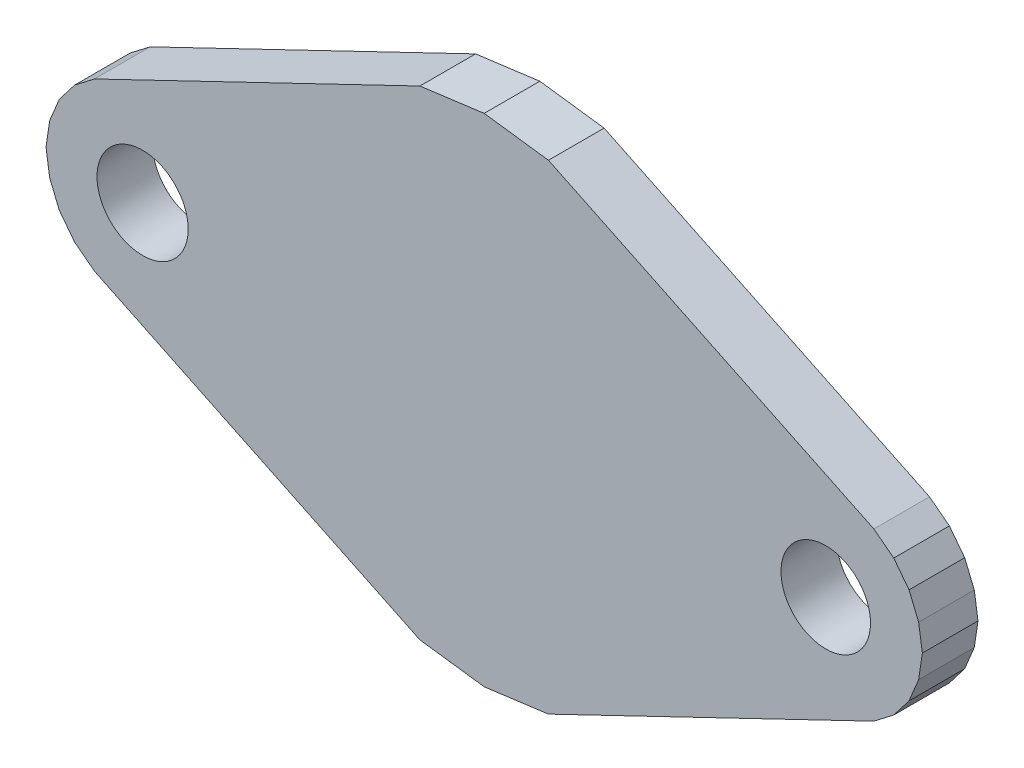
from build123d import *

# Parameters (mm, degrees)
ESBO_O1_R                = 2.458273609
ESBO_O1_R_2              = 2.41299998
RESSALTO_EXTRUS_O2_DEPTH = 3


with BuildPart() as part:
    # Esboço1 → Ressalto-extrusão2 (new body)
    with BuildSketch(Plane.XY):
        Polygon((-3.440879294, 5.164211145), (0.023622001, 5.620321217), (0.023622001, -21.15127821), (-3.440879351, -20.69516813), (-20.982927009, -12.254172046), (-22.056381633, -11.43048149), (-22.880072189, -10.357026984), (-23.397865785, -9.106962052), (-23.598378589, -7.765478496), (-23.397865785, -6.423994009), (-22.880072189, -5.173929077), (-22.056381633, -4.100475502), (-20.982927009, -3.276784015), align=None)
        with Locations((-18.391378755, -7.765478496)):
            Circle(ESBO_O1_R, mode=Mode.SUBTRACT)
        Polygon((0.023622001, 5.620321217), (3.488123295, 5.164211145), (21.030171011, -3.276784015), (22.103625634, -4.100475502), (22.92731619, -5.173929077), (23.445109786, -6.423994009), (23.645622591, -7.765478496), (23.445109786, -9.106962052), (22.92731619, -10.357026984), (22.103625634, -11.43048149), (21.030171011, -12.254172046), (3.488123352, -20.69516813), (0.023622001, -21.15127821), align=None)
        with Locations((18.438620428, -7.765478496)):
            Circle(ESBO_O1_R_2, mode=Mode.SUBTRACT)
    extrude(amount=RESSALTO_EXTRUS_O2_DEPTH)


solid = part.part
